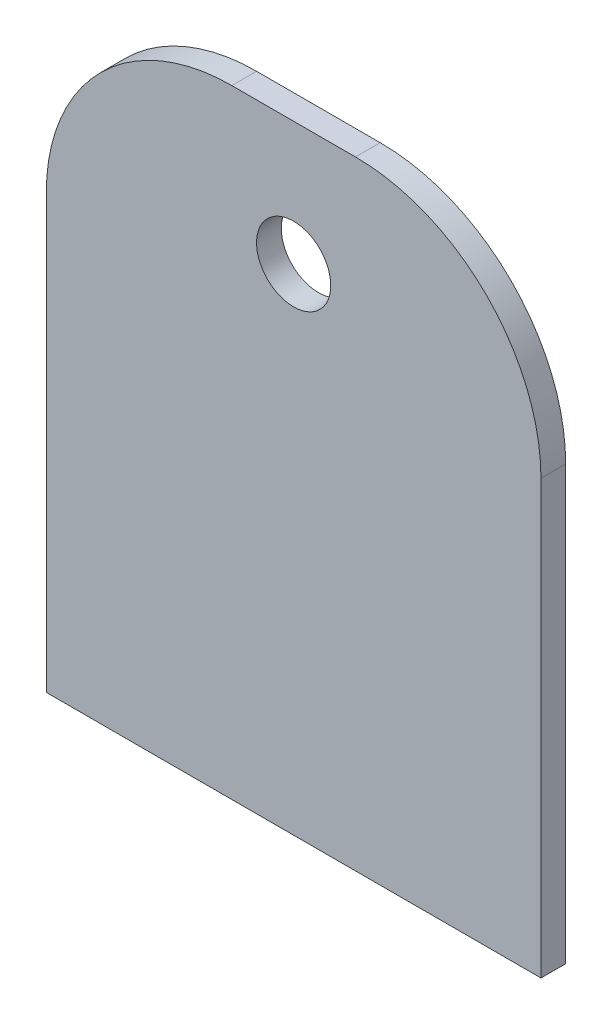
from build123d import *

# Parameters (mm, degrees)
SZKIC1_R                    = 3
DODANIE_WYCI_GNI_CIE1_DEPTH = 2


with BuildPart() as part:
    # Szkic1 → Dodanie-wyciągnięcie1 (new body)
    with BuildSketch(Plane.XY):
        with BuildLine():
            Line((0, 0), (-40, 0))
            Line((-40, 0), (-40, 35))
            ThreePointArc((-40, 35), (-35.606601718, 45.606601718), (-25, 50))
            Line((-25, 50), (-15, 50))
            ThreePointArc((-15, 50), (-4.393398282, 45.606601718), (0, 35))
            Line((0, 35), (0, 0))
        make_face()
        with Locations((-20, 40)):
            Circle(SZKIC1_R, mode=Mode.SUBTRACT)
    extrude(amount=DODANIE_WYCI_GNI_CIE1_DEPTH)


solid = part.part
